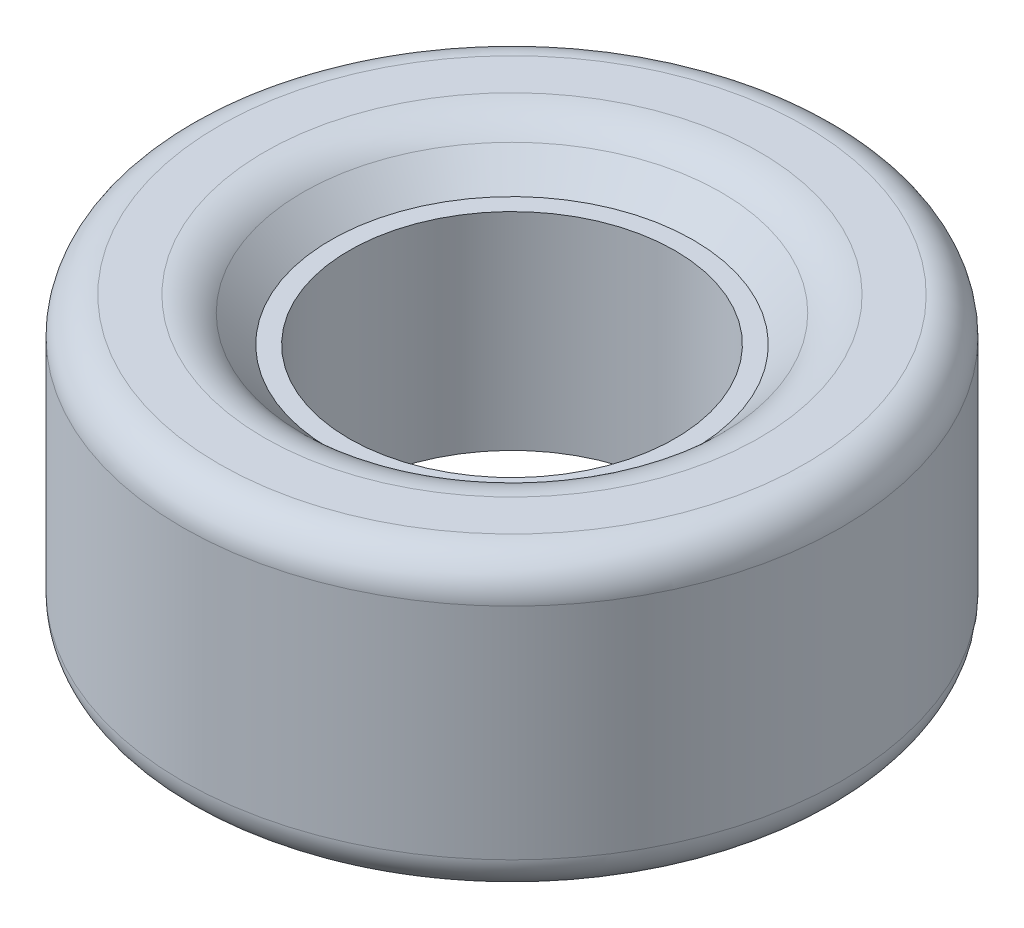
from build123d import *

# Parameters (mm, degrees)
SKETCH1_R           = 90
SKETCH1_R_2         = 44.5
BOSS_EXTRUDE1_DEPTH = 80
FILLET1_R           = 15
FILLET2_R           = 10


with BuildPart() as part:
    # Sketch1 → Boss-Extrude1 (new body)
    with BuildSketch(Plane(origin=(0, 0, 0), x_dir=(1, 0, 0), z_dir=(0, 1, 0))):
        Circle(SKETCH1_R)
        Circle(SKETCH1_R_2, mode=Mode.SUBTRACT)
    extrude(amount=BOSS_EXTRUDE1_DEPTH)

    # Sketch2 → Cut-Revolve1 (revolve, cut)
    with BuildSketch(Plane.XY):
        Polygon((61.5, 0), (49.5, 11.75), (44.5, 11.75), (44.5, 0), align=None)
    cut_revolve1 = revolve(axis=Axis((0, 0, 0), (0, 1, 0)), mode=Mode.SUBTRACT)

    # Mirror1: Cut-Revolve1 across plane
    add(cut_revolve1.mirror(Plane(origin=(0, 40, 0), x_dir=(0, 0, 1), z_dir=(0, -1, 0))), mode=Mode.SUBTRACT)

    # Fillet1
    fillet1_edges = [part.edges().sort_by_distance(p)[0] for p in [
        (-61.5, 0, 0),
        (-61.5, 80, 0),
    ]]
    fillet(fillet1_edges, radius=FILLET1_R)

    # Fillet2
    fillet2_edges = [part.edges().sort_by_distance(p)[0] for p in [
        (-90, 0, 0),
        (-90, 80, 0),
    ]]
    fillet(fillet2_edges, radius=FILLET2_R)


solid = part.part
